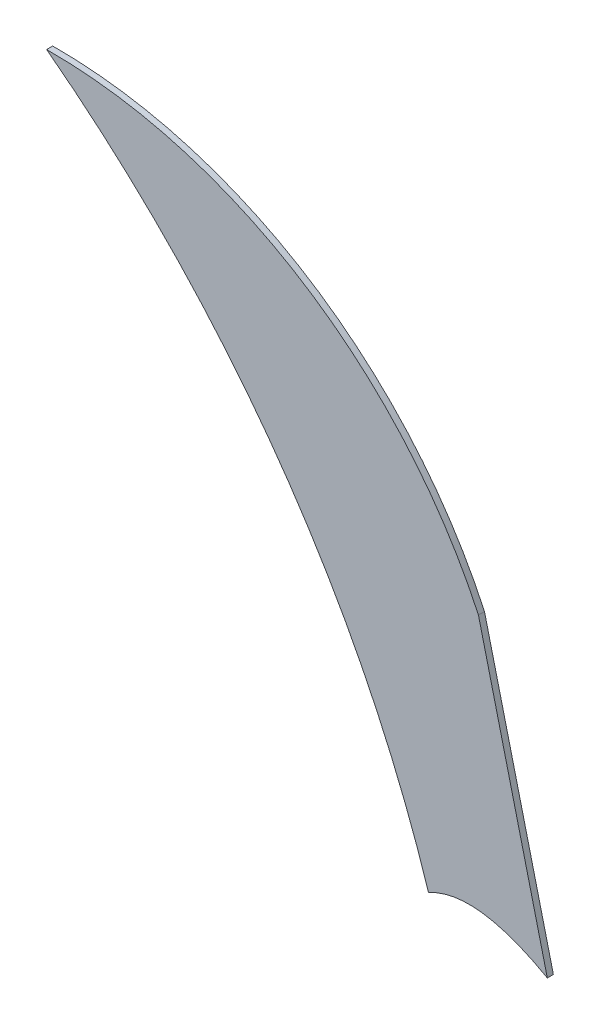
from build123d import *

# Parameters (mm, degrees)
SALIENTE_EXTRUIR1_DEPTH = 0.1


with BuildPart() as part:
    # Model → Saliente-Extruir1 (new body)
    with BuildSketch(Plane.XY):
        with BuildLine():
            ThreePointArc((37.911410496, 21.306897051), (35.008532901, 24.616100687), (30.77744569, 25.83077268))
            ThreePointArc((30.77744569, 25.83077268), (34.621025182, 21.865331343), (37.086298445, 16.923645795))
            add(Edge.make_bspline(
                [(39.04988231, 16.682558191), (37.86622829, 17.351962219), (37.086298445, 16.923645795)],
                knots=[1, 1, 1, 1.517629094, 1.517629094, 1.517629094], degree=2))
            add(Edge.make_bspline(
                [(37.911410496, 21.306897051), (38.480646403, 18.994727621), (39.04988231, 16.682558191)],
                knots=[0, 0, 0, 1, 1, 1], degree=2))
        make_face()
    extrude(amount=SALIENTE_EXTRUIR1_DEPTH)


solid = part.part
